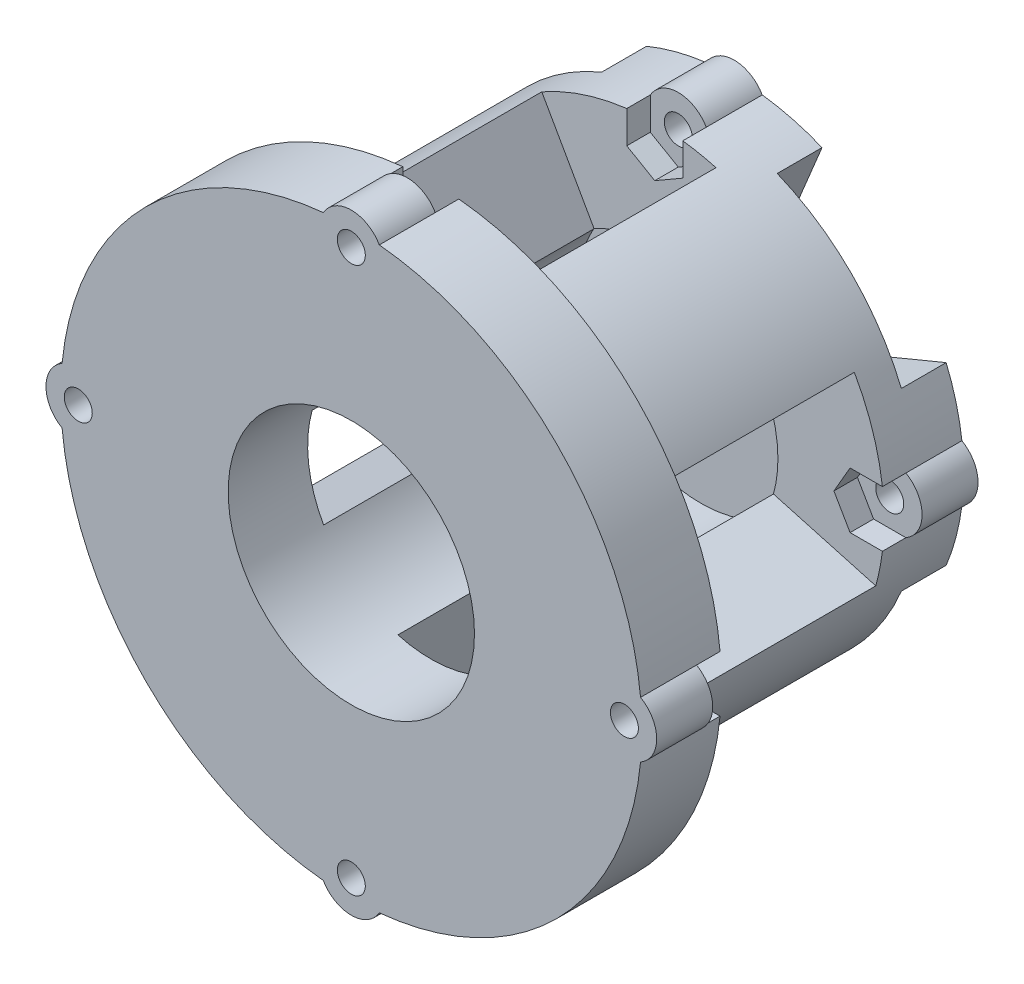
from build123d import *
from build123d.topology import SkipClean

# Parameters (mm, degrees)
SKETCH1_R           = 1.25
SKETCH1_R_2         = 11
BOSS_EXTRUDE1_DEPTH = 2
BOSS_EXTRUDE2_START = -3
SKETCH1_3_R         = 1.25
SKETCH1_3_R_2       = 3
BOSS_EXTRUDE2_DEPTH = 3
SKETCH7_R           = 11
BOSS_EXTRUDE6_DEPTH = 2.1
CUT_EXTRUDE1_DEPTH  = 4
BOSS_EXTRUDE3_DEPTH = 20
SKETCH5_R           = 11
BOSS_EXTRUDE4_DEPTH = 2.1
SKETCH9_R           = 1.25
SKETCH9_R_2         = 11
BOSS_EXTRUDE8_DEPTH = 5


with BuildPart() as part:
    # Sketch1 → Boss-Extrude1 (new body)
    with BuildSketch(Plane.XY):
        with BuildLine():
            ThreePointArc((2.5, -20.330127019), (14.483854194, -14.483854194), (20.330127019, -2.5))
            ThreePointArc((20.330127019, -2.5), (21.773502692, 0), (20.330127019, 2.5))
            ThreePointArc((20.330127019, 2.5), (14.483854194, 14.483854194), (2.5, 20.330127019))
            ThreePointArc((2.5, 20.330127019), (0, 21.773502692), (-2.5, 20.330127019))
            ThreePointArc((-2.5, 20.330127019), (-14.483854194, 14.483854194), (-20.330127019, 2.5))
            ThreePointArc((-20.330127019, 2.5), (-21.773502692, 0), (-20.330127019, -2.5))
            ThreePointArc((-20.330127019, -2.5), (-14.483854194, -14.483854194), (-2.5, -20.330127019))
            ThreePointArc((-2.5, -20.330127019), (0, -21.773502692), (2.5, -20.330127019))
        make_face()
        with Locations((-18.886751346, 0)):
            Circle(SKETCH1_R, mode=Mode.SUBTRACT)
        with Locations((0, -18.886751346)):
            Circle(SKETCH1_R, mode=Mode.SUBTRACT)
        with Locations((0, 18.886751346)):
            Circle(SKETCH1_R, mode=Mode.SUBTRACT)
        Circle(SKETCH1_R_2, mode=Mode.SUBTRACT)
        with Locations((18.886751346, 0)):
            Circle(SKETCH1_R, mode=Mode.SUBTRACT)
    extrude(amount=BOSS_EXTRUDE1_DEPTH)

    # Sketch1_3 → Boss-Extrude2 (add)
    with BuildSketch(Plane.XY.offset(BOSS_EXTRUDE2_START)):
        with BuildLine():
            ThreePointArc((2.5, -20.330127019), (14.483854194, -14.483854194), (20.330127019, -2.5))
            ThreePointArc((20.330127019, -2.5), (21.773502692, 0), (20.330127019, 2.5))
            ThreePointArc((20.330127019, 2.5), (14.483854194, 14.483854194), (2.5, 20.330127019))
            ThreePointArc((2.5, 20.330127019), (0, 21.773502692), (-2.5, 20.330127019))
            ThreePointArc((-2.5, 20.330127019), (-14.483854194, 14.483854194), (-20.330127019, 2.5))
            ThreePointArc((-20.330127019, 2.5), (-21.773502692, 0), (-20.330127019, -2.5))
            ThreePointArc((-20.330127019, -2.5), (-14.483854194, -14.483854194), (-2.5, -20.330127019))
            ThreePointArc((-2.5, -20.330127019), (0, -21.773502692), (2.5, -20.330127019))
        make_face()
        with Locations((-18.886751346, 0)):
            Circle(SKETCH1_3_R, mode=Mode.SUBTRACT)
        with Locations((0, -18.886751346)):
            Circle(SKETCH1_3_R, mode=Mode.SUBTRACT)
        with Locations((0, 18.886751346)):
            Circle(SKETCH1_3_R, mode=Mode.SUBTRACT)
        with Locations((18.886751346, 0)):
            Circle(SKETCH1_3_R, mode=Mode.SUBTRACT)
        Circle(SKETCH1_3_R_2, mode=Mode.SUBTRACT)
    extrude(amount=BOSS_EXTRUDE2_DEPTH)

    # Sketch7 → Boss-Extrude6 (add)
    with BuildSketch(Plane.XY.offset(2)):
        with BuildLine():
            Line((17.443375673, 2.5), (20.330127019, 2.5))
            ThreePointArc((20.330127019, 2.5), (14.483854194, 14.483854194), (2.5, 20.330127019))
            Line((2.5, 20.330127019), (2.5, 17.443375673))
            Line((2.5, 17.443375673), (0, 16))
            Line((0, 16), (-2.5, 17.443375673))
            Line((-2.5, 17.443375673), (-2.5, 20.330127019))
            ThreePointArc((-2.5, 20.330127019), (-14.483854194, 14.483854194), (-20.330127019, 2.5))
            Line((-20.330127019, 2.5), (-17.443375673, 2.5))
            Line((-17.443375673, 2.5), (-16, 0))
            Line((-16, 0), (-17.443375673, -2.5))
            Line((-17.443375673, -2.5), (-20.330127019, -2.5))
            ThreePointArc((-20.330127019, -2.5), (-14.483854194, -14.483854194), (-2.5, -20.330127019))
            Line((-2.5, -20.330127019), (-2.5, -17.443375673))
            Line((-2.5, -17.443375673), (0, -16))
            Line((0, -16), (2.5, -17.443375673))
            Line((2.5, -17.443375673), (2.5, -20.330127019))
            ThreePointArc((2.5, -20.330127019), (14.483854194, -14.483854194), (20.330127019, -2.5))
            Line((20.330127019, -2.5), (17.443375673, -2.5))
            Line((17.443375673, -2.5), (16, 0))
            Line((16, 0), (17.443375673, 2.5))
        make_face()
        Circle(SKETCH7_R, mode=Mode.SUBTRACT)
    extrude(amount=BOSS_EXTRUDE6_DEPTH)

    # Sketch8 → Cut-Extrude1 (cut)
    with BuildSketch(Plane(origin=(0, 0, -3), x_dir=(-1, 0, 0), z_dir=(0, 0, -1))):
        with BuildLine():
            Line((-5.357568053, 12.934313455), (-7.838605405, 18.924067478))
            ThreePointArc((-7.838605405, 18.924067478), (-14.483854194, 14.483854194), (-18.924067478, 7.838605405))
            Line((-18.924067478, 7.838605405), (-12.934313455, 5.357568053))
            ThreePointArc((-12.934313455, 5.357568053), (-9.899494937, 9.899494937), (-5.357568053, 12.934313455))
        make_face()
        with BuildLine():
            Line((12.934313455, 5.357568053), (18.924067478, 7.838605405))
            ThreePointArc((18.924067478, 7.838605405), (14.483854194, 14.483854194), (7.838605405, 18.924067478))
            Line((7.838605405, 18.924067478), (5.357568053, 12.934313455))
            ThreePointArc((5.357568053, 12.934313455), (9.899494937, 9.899494937), (12.934313455, 5.357568053))
        make_face()
        with BuildLine():
            Line((5.357568053, -12.934313455), (7.838605405, -18.924067478))
            ThreePointArc((7.838605405, -18.924067478), (14.483854194, -14.483854194), (18.924067478, -7.838605405))
            Line((18.924067478, -7.838605405), (12.934313455, -5.357568053))
            ThreePointArc((12.934313455, -5.357568053), (9.899494937, -9.899494937), (5.357568053, -12.934313455))
        make_face()
        with BuildLine():
            Line((-12.934313455, -5.357568053), (-18.924067478, -7.838605405))
            ThreePointArc((-18.924067478, -7.838605405), (-14.483854194, -14.483854194), (-7.838605405, -18.924067478))
            Line((-7.838605405, -18.924067478), (-5.357568053, -12.934313455))
            ThreePointArc((-5.357568053, -12.934313455), (-9.899494937, -9.899494937), (-12.934313455, -5.357568053))
        make_face()
    extrude(amount=-CUT_EXTRUDE1_DEPTH, mode=Mode.SUBTRACT)

    # Sketch2 → Boss-Extrude3 (add)
    with SkipClean():  # the faces are left unmerged after this step: merging them gives an invalid solid
        with BuildSketch(Plane.XY.offset(4.1)):
            with BuildLine():
                Line((-5.418410027, 9.572921852), (-10.089701619, 17.825879665))
                ThreePointArc((-10.089701619, 17.825879665), (-16.14333763, 12.607803724), (-19.739296827, 5.470303957))
                Line((-19.739296827, 5.470303957), (-10.60047243, 2.937683484))
                ThreePointArc((-10.60047243, 2.937683484), (-8.669356714, 6.770690818), (-5.418410027, 9.572921852))
            make_face()
            with BuildLine():
                ThreePointArc((17.825879665, 10.089701619), (12.607803724, 16.14333763), (5.470303957, 19.739296827))
                Line((5.470303957, 19.739296827), (2.937683484, 10.60047243))
                ThreePointArc((2.937683484, 10.60047243), (6.770690818, 8.669356714), (9.572921852, 5.418410027))
                Line((9.572921852, 5.418410027), (17.825879665, 10.089701619))
            make_face()
            with BuildLine():
                ThreePointArc((10.089701619, -17.825879665), (16.14333763, -12.607803724), (19.739296827, -5.470303957))
                Line((19.739296827, -5.470303957), (10.60047243, -2.937683484))
                ThreePointArc((10.60047243, -2.937683484), (8.669356714, -6.770690818), (5.418410027, -9.572921852))
                Line((5.418410027, -9.572921852), (10.089701619, -17.825879665))
            make_face()
            with BuildLine():
                ThreePointArc((-17.825879665, -10.089701619), (-12.607803724, -16.14333763), (-5.470303957, -19.739296827))
                Line((-5.470303957, -19.739296827), (-2.937683484, -10.60047243))
                ThreePointArc((-2.937683484, -10.60047243), (-6.770690818, -8.669356714), (-9.572921852, -5.418410027))
                Line((-9.572921852, -5.418410027), (-17.825879665, -10.089701619))
            make_face()
        extrude(amount=BOSS_EXTRUDE3_DEPTH)

    # Sketch5 → Boss-Extrude4 (add)
    with SkipClean():  # the faces are left unmerged after this step: merging them gives an invalid solid
        with BuildSketch(Plane.XY.offset(24.1)):
            with BuildLine():
                Line((22.943375673, 2.5), (25.830127019, 2.5))
                ThreePointArc((25.830127019, 2.5), (18.350006292, 18.350006292), (2.5, 25.830127019))
                Line((2.5, 25.830127019), (2.5, 22.943375673))
                Line((2.5, 22.943375673), (0, 21.5))
                Line((0, 21.5), (-2.5, 22.943375673))
                Line((-2.5, 22.943375673), (-2.5, 25.830127019))
                ThreePointArc((-2.5, 25.830127019), (-18.350006292, 18.350006292), (-25.830127019, 2.5))
                Line((-25.830127019, 2.5), (-22.943375673, 2.5))
                Line((-22.943375673, 2.5), (-21.5, 0))
                Line((-21.5, 0), (-22.943375673, -2.5))
                Line((-22.943375673, -2.5), (-25.830127019, -2.5))
                ThreePointArc((-25.830127019, -2.5), (-18.350006292, -18.350006292), (-2.5, -25.830127019))
                Line((-2.5, -25.830127019), (-2.5, -22.943375673))
                Line((-2.5, -22.943375673), (0, -21.5))
                Line((0, -21.5), (2.5, -22.943375673))
                Line((2.5, -22.943375673), (2.5, -25.830127019))
                ThreePointArc((2.5, -25.830127019), (18.350006292, -18.350006292), (25.830127019, -2.5))
                Line((25.830127019, -2.5), (22.943375673, -2.5))
                Line((22.943375673, -2.5), (21.5, 0))
                Line((21.5, 0), (22.943375673, 2.5))
            make_face()
            Circle(SKETCH5_R, mode=Mode.SUBTRACT)
        extrude(amount=BOSS_EXTRUDE4_DEPTH)

    # Sketch9 → Boss-Extrude8 (add)
    with SkipClean():  # the faces are left unmerged after this step: merging them gives an invalid solid
        with BuildSketch(Plane.XY.offset(26.2)):
            with BuildLine():
                ThreePointArc((2.5, 25.830127019), (0, 27.273502692), (-2.5, 25.830127019))
                ThreePointArc((-2.5, 25.830127019), (-18.350006292, 18.350006292), (-25.830127019, 2.5))
                ThreePointArc((-25.830127019, 2.5), (-27.273502692, 0), (-25.830127019, -2.5))
                ThreePointArc((-25.830127019, -2.5), (-18.350006292, -18.350006292), (-2.5, -25.830127019))
                ThreePointArc((-2.5, -25.830127019), (0, -27.273502692), (2.5, -25.830127019))
                ThreePointArc((2.5, -25.830127019), (18.350006292, -18.350006292), (25.830127019, -2.5))
                ThreePointArc((25.830127019, -2.5), (27.273502692, 0), (25.830127019, 2.5))
                ThreePointArc((25.830127019, 2.5), (18.350006292, 18.350006292), (2.5, 25.830127019))
            make_face()
            with Locations((0, 24.386751346)):
                Circle(SKETCH9_R, mode=Mode.SUBTRACT)
            Circle(SKETCH9_R_2, mode=Mode.SUBTRACT)
            with Locations((-24.386751346, 0)):
                Circle(SKETCH9_R, mode=Mode.SUBTRACT)
            with Locations((24.386751346, 0)):
                Circle(SKETCH9_R, mode=Mode.SUBTRACT)
            with Locations((0, -24.386751346)):
                Circle(SKETCH9_R, mode=Mode.SUBTRACT)
        extrude(amount=BOSS_EXTRUDE8_DEPTH)


solid = part.part
